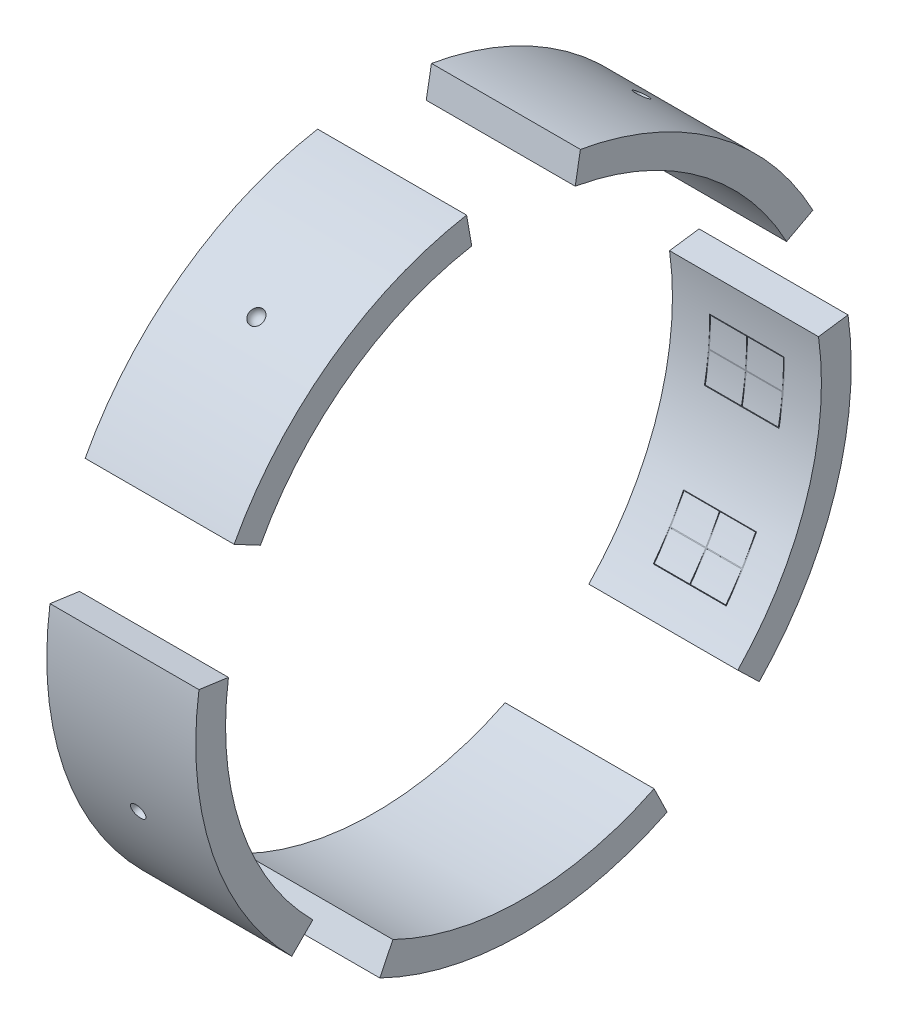
from build123d import *

# Parameters (mm, degrees)
BOSS_EXTRUDE1_DEPTH              = 100
BOSS_EXTRUDE1_2_DEPTH            = 100
BOSS_EXTRUDE1_3_DEPTH            = 100
BOSS_EXTRUDE1_4_DEPTH            = 100
BOSS_EXTRUDE1_5_DEPTH            = 100
F_1_2_13_TAPPED_HOLE1_AT_2_COUNT = 2
F_1_2_13_TAPPED_HOLE1_AT_2_PITCH = 94.479443
F_1_2_13_TAPPED_HOLE1_AT_3_COUNT = 2
F_1_2_13_TAPPED_HOLE1_AT_3_PITCH = 164.107074
F_1_2_13_TAPPED_HOLE1_AT_4_COUNT = 2
F_1_2_13_TAPPED_HOLE1_AT_4_PITCH = 246.869806
F_1_2_13_TAPPED_HOLE1_AT_5_COUNT = 2
F_1_2_13_TAPPED_HOLE1_AT_5_PITCH = 361.224207
F_1_2_13_TAPPED_HOLE1_AT_6_COUNT = 2
F_1_2_13_TAPPED_HOLE1_AT_6_PITCH = 400.096421
F_1_2_13_TAPPED_HOLE1_AT_7_COUNT = 2
F_1_2_13_TAPPED_HOLE1_AT_7_PITCH = 418.401773
F_1_2_13_TAPPED_HOLE1_AT_8_COUNT = 2
F_1_2_13_TAPPED_HOLE1_AT_8_PITCH = 246.869806
F_1_2_13_TAPPED_HOLE1_AT_9_COUNT = 2
F_1_2_13_TAPPED_HOLE1_AT_9_PITCH = 316.978024
SKETCH10_W                       = 50.099594
SKETCH10_H                       = 39.875188
SKETCH10_W_2                     = 49
SKETCH10_H_2                     = 39
CUT_EXTRUDE6_DEPTH               = 22
CUT_EXTRUDE7_DEPTH               = 28
SKETCH12_W                       = 48.963362
SKETCH12_H                       = 38.762661
SKETCH12_W_2                     = 48
SKETCH12_H_2                     = 38
CUT_EXTRUDE10_DEPTH              = 11
CUT_EXTRUDE11_DEPTH              = 10


with BuildPart() as part:
    # Sketch1 → Boss-Extrude1 (new body)
    with BuildSketch(Plane(origin=(0, 0, 0), x_dir=(0, 0, -1), z_dir=(1, 0, 0))):
        with BuildLine():
            Line((87.674229, -179.758809), (96.441652, -197.73469))
            ThreePointArc((96.441652, -197.73469), (0, -220), (-96.441652, -197.73469))
            Line((-96.441652, -197.73469), (-87.674229, -179.758809))
            ThreePointArc((-87.674229, -179.758809), (0, -200), (87.674229, -179.758809))
        make_face()
    extrude(amount=BOSS_EXTRUDE1_DEPTH)

    # Sketch6 → Cut-Revolve4 (revolve, cut)
    with BuildSketch(Plane(origin=(0, -220, 0), x_dir=(-1, 0, 0), z_dir=(0, -1, 0))):
        with BuildLine():
            Line((-55, 0), (-45, 0))
            ThreePointArc((-45, 0), (-50, -5), (-55, 0))
        make_face()
    revolve(axis=Axis((55, -220, 0), (-1, 0, 0)), mode=Mode.SUBTRACT)


with BuildPart() as body_2:
    # Sketch1 → Boss-Extrude1 2 (new body)
    with BuildSketch(Plane(origin=(0, 0, 0), x_dir=(0, 0, -1), z_dir=(1, 0, 0))):
        with BuildLine():
            Line((143.86796, -138.931674), (158.254756, -152.824842))
            ThreePointArc((158.254756, -152.824842), (209.232434, -67.983739), (217.858975, 30.618082))
            Line((217.858975, 30.618082), (198.053614, 27.83462))
            ThreePointArc((198.053614, 27.83462), (190.211303, -61.803399), (143.86796, -138.931674))
        make_face()
    extrude(amount=BOSS_EXTRUDE1_2_DEPTH)

    # Sketch5 → Cut-Revolve3 (revolve, cut)
    with BuildSketch(Plane(origin=(0, -67.983739, -209.232434), x_dir=(-1, 0, 0), z_dir=(0, -0.309017, -0.951057))):
        with BuildLine():
            Line((-55, 0), (-45, 0))
            ThreePointArc((-45, 0), (-50, 5), (-55, 0))
        make_face()
    revolve(axis=Axis((55, -67.983739, -209.232434), (-1, 0, 0)), mode=Mode.SUBTRACT)

    # Sketch9 → 1/2-13 Tapped Hole1 (revolve, cut)
    with BuildSketch(Plane(origin=(-10, -108.157996, -180.005133), x_dir=(0, 0, 1), z_dir=(0, 1, 0))):
        Polygon((0, 0), (0, 69.119489), (5.35813, 65.9), (5.35813, 0), align=None)
    f_1_2_13_tapped_hole1 = revolve(axis=Axis((-16.35, -108.157996, -180.005133), (1, 0, 0)), mode=Mode.SUBTRACT)

    # 1/2-13 Tapped Hole1 at 2: 1/2-13 Tapped Hole1 ×2
    with Locations(*[Vector(0, 0.951057, -0.309017) * (i * F_1_2_13_TAPPED_HOLE1_AT_2_PITCH) for i in range(1, F_1_2_13_TAPPED_HOLE1_AT_2_COUNT)]):
        add(f_1_2_13_tapped_hole1, mode=Mode.SUBTRACT)

    # Sketch10 → Cut-Extrude6 (cut)
    with BuildSketch(Plane(origin=(-10, -17.431149, -199.23894), x_dir=(1, 0, 0), z_dir=(0, 0.087156, 0.996195))):
        with Locations((60, 0)):
            Rectangle(SKETCH10_W, SKETCH10_H)
        with Locations((60, 0)):
            Rectangle(SKETCH10_W_2, SKETCH10_H_2, mode=Mode.SUBTRACT)
    extrude(amount=CUT_EXTRUDE6_DEPTH, mode=Mode.SUBTRACT)

    # Sketch11 → Cut-Extrude7 (cut)
    with BuildSketch(Plane(origin=(-10, -17.431149, -199.23894), x_dir=(1, 0, 0), z_dir=(0, 0.087156, 0.996195))):
        Polygon((35.5, 0.25), (59.75, 0.25), (59.75, 19.5), (60.25, 19.5), (60.25, 0.25), (84.5, 0.25), (84.5, -0.25), (60.25, -0.25), (60.25, -19.5), (59.75, -19.5), (59.75, -0.25), (35.5, -0.25), align=None)
    extrude(amount=CUT_EXTRUDE7_DEPTH, mode=Mode.SUBTRACT)

    # Sketch12 → Cut-Extrude10 (cut)
    with BuildSketch(Plane(origin=(-10, -103.007615, -171.43346), x_dir=(1, 0, 0), z_dir=(0, 0.515038, 0.857167))):
        with Locations((62.313641, -2.262464)):
            Rectangle(SKETCH12_W, SKETCH12_H)
        with Locations((62.313641, -2.262463)):
            Rectangle(SKETCH12_W_2, SKETCH12_H_2, mode=Mode.SUBTRACT)
    extrude(amount=CUT_EXTRUDE10_DEPTH, mode=Mode.SUBTRACT)

    # Sketch13 → Cut-Extrude11 (cut)
    with BuildSketch(Plane(origin=(-10, -103.007615, -171.43346), x_dir=(1, 0, 0), z_dir=(0, 0.515038, 0.857167))):
        Polygon((38.313641, -2.012463), (62.063641, -2.012463), (62.063641, 16.737537), (62.563641, 16.737537), (62.563641, -2.012463), (86.313641, -2.012463), (86.313641, -2.512463), (62.563641, -2.512463), (62.563641, -21.262463), (62.063641, -21.262463), (62.063641, -2.512463), (38.313641, -2.512463), align=None)
    extrude(amount=CUT_EXTRUDE11_DEPTH, mode=Mode.SUBTRACT)


with BuildPart() as body_3:
    # Sketch1 → Boss-Extrude1 3 (new body)
    with BuildSketch(Plane(origin=(0, 0, 0), x_dir=(0, 0, -1), z_dir=(1, 0, 0))):
        with BuildLine():
            Line((176.589519, 93.894313), (194.24847, 103.283744))
            ThreePointArc((194.24847, 103.283744), (129.312756, 177.983739), (38.202599, 216.657706))
            Line((38.202599, 216.657706), (34.729636, 196.961551))
            ThreePointArc((34.729636, 196.961551), (117.55705, 161.803399), (176.589519, 93.894313))
        make_face()
    extrude(amount=BOSS_EXTRUDE1_3_DEPTH)

    # Sketch4 → Cut-Revolve2 (revolve, cut)
    with BuildSketch(Plane(origin=(0, 177.983739, -129.312756), x_dir=(1, 0, 0), z_dir=(0, 0.809017, -0.587785))):
        with BuildLine():
            Line((45, 0), (55, 0))
            ThreePointArc((55, 0), (50, 5), (45, 0))
        make_face()
    revolve(axis=Axis((45, 177.983739, -129.312756), (1, 0, 0)), mode=Mode.SUBTRACT)

    # 1/2-13 Tapped Hole1 at 8: 1/2-13 Tapped Hole1 ×2
    with Locations(*[Vector(0, 0.996195, 0.087156) * (i * F_1_2_13_TAPPED_HOLE1_AT_8_PITCH) for i in range(1, F_1_2_13_TAPPED_HOLE1_AT_8_COUNT)]):
        add(f_1_2_13_tapped_hole1, mode=Mode.SUBTRACT)

    # 1/2-13 Tapped Hole1 at 9: 1/2-13 Tapped Hole1 ×2
    with Locations(*[Vector(0, 0.951057, 0.309017) * (i * F_1_2_13_TAPPED_HOLE1_AT_9_PITCH) for i in range(1, F_1_2_13_TAPPED_HOLE1_AT_9_COUNT)]):
        add(f_1_2_13_tapped_hole1, mode=Mode.SUBTRACT)


with BuildPart() as body_4:
    # Sketch1 → Boss-Extrude1 4 (new body)
    with BuildSketch(Plane(origin=(0, 0, 0), x_dir=(0, 0, -1), z_dir=(1, 0, 0))):
        with BuildLine():
            Line((-34.729636, 196.961551), (-38.202599, 216.657706))
            ThreePointArc((-38.202599, 216.657706), (-129.312756, 177.983739), (-194.24847, 103.283744))
            Line((-194.24847, 103.283744), (-176.589519, 93.894313))
            ThreePointArc((-176.589519, 93.894313), (-117.55705, 161.803399), (-34.729636, 196.961551))
        make_face()
    extrude(amount=BOSS_EXTRUDE1_4_DEPTH)

    # Sketch2 → Cut-Revolve1 (revolve, cut)
    with BuildSketch(Plane(origin=(0, 177.983739, 129.312756), x_dir=(1, 0, 0), z_dir=(0, 0.809017, 0.587785))):
        with BuildLine():
            Line((45, 0), (55, 0))
            ThreePointArc((55, 0), (50, 5), (45, 0))
        make_face()
    revolve(axis=Axis((45, 177.983739, 129.312756), (1, 0, 0)), mode=Mode.SUBTRACT)

    # 1/2-13 Tapped Hole1 at 7: 1/2-13 Tapped Hole1 ×2
    with Locations(*[Vector(0, 0.587785, 0.809017) * (i * F_1_2_13_TAPPED_HOLE1_AT_7_PITCH) for i in range(1, F_1_2_13_TAPPED_HOLE1_AT_7_COUNT)]):
        add(f_1_2_13_tapped_hole1, mode=Mode.SUBTRACT)


with BuildPart() as body_5:
    # Sketch1 → Boss-Extrude1 5 (new body)
    with BuildSketch(Plane(origin=(0, 0, 0), x_dir=(0, 0, -1), z_dir=(1, 0, 0))):
        with BuildLine():
            Line((-198.053614, 27.83462), (-217.858975, 30.618082))
            ThreePointArc((-217.858975, 30.618082), (-208.631204, -69.807024), (-155.563492, -155.563492))
            Line((-155.563492, -155.563492), (-141.421356, -141.421356))
            ThreePointArc((-141.421356, -141.421356), (-189.664731, -63.460931), (-198.053614, 27.83462))
        make_face()
    extrude(amount=BOSS_EXTRUDE1_5_DEPTH)

    # Sketch7 → Cut-Revolve5 (revolve, cut)
    with BuildSketch(Plane(origin=(0, -69.807024, 208.631204), x_dir=(1, 0, 0), z_dir=(0, -0.317305, 0.948324))):
        with BuildLine():
            Line((45, 0), (55, 0))
            ThreePointArc((55, 0), (50, 5), (45, 0))
        make_face()
    revolve(axis=Axis((45, -69.807024, 208.631204), (1, 0, 0)), mode=Mode.SUBTRACT)

    # 1/2-13 Tapped Hole1 at 5: 1/2-13 Tapped Hole1 ×2
    with Locations(*[Vector(0, 0.007884, 0.999969) * (i * F_1_2_13_TAPPED_HOLE1_AT_5_PITCH) for i in range(1, F_1_2_13_TAPPED_HOLE1_AT_5_COUNT)]):
        add(f_1_2_13_tapped_hole1, mode=Mode.SUBTRACT)

    # 1/2-13 Tapped Hole1 at 6: 1/2-13 Tapped Hole1 ×2
    with Locations(*[Vector(0, 0.229898, 0.973215) * (i * F_1_2_13_TAPPED_HOLE1_AT_6_PITCH) for i in range(1, F_1_2_13_TAPPED_HOLE1_AT_6_COUNT)]):
        add(f_1_2_13_tapped_hole1, mode=Mode.SUBTRACT)


with BuildPart() as part_1:
    add(part.part)

    # 1/2-13 Tapped Hole1 at 3: 1/2-13 Tapped Hole1 ×2
    with Locations(*[Vector(0, -0.587785, 0.809017) * (i * F_1_2_13_TAPPED_HOLE1_AT_3_PITCH) for i in range(1, F_1_2_13_TAPPED_HOLE1_AT_3_COUNT)]):
        add(f_1_2_13_tapped_hole1, mode=Mode.SUBTRACT)

    # 1/2-13 Tapped Hole1 at 4: 1/2-13 Tapped Hole1 ×2
    with Locations(*[Vector(0, -0.390731, 0.920505) * (i * F_1_2_13_TAPPED_HOLE1_AT_4_PITCH) for i in range(1, F_1_2_13_TAPPED_HOLE1_AT_4_COUNT)]):
        add(f_1_2_13_tapped_hole1, mode=Mode.SUBTRACT)


solid = Compound([body_2.part, body_3.part, body_4.part, body_5.part, part_1.part])
